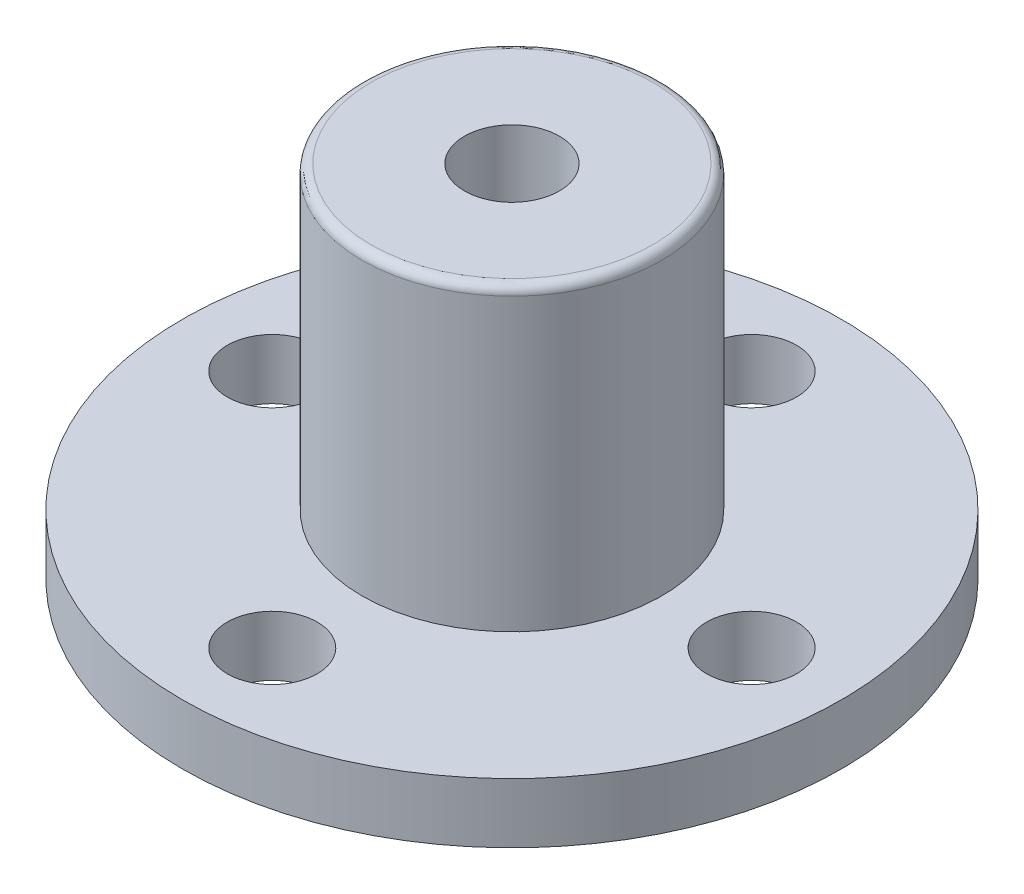
from build123d import *

# Parameters (mm, degrees)
SKETCH1_R           = 11
BOSS_EXTRUDE1_DEPTH = 2
SKETCH2_R           = 5
BOSS_EXTRUDE2_DEPTH = 10
FILLET1_R           = 0.3
SKETCH3_R           = 1.5
CUT_EXTRUDE1_DEPTH  = 10
SKETCH4_R           = 1.585
CUT_EXTRUDE2_DEPTH  = 20


with BuildPart() as part:
    # Sketch1 → Boss-Extrude1 (new body)
    with BuildSketch(Plane(origin=(0, 0, 0), x_dir=(1, 0, 0), z_dir=(0, 1, 0))):
        Circle(SKETCH1_R)
    extrude(amount=BOSS_EXTRUDE1_DEPTH)

    # Sketch2 → Boss-Extrude2 (add)
    with BuildSketch(Plane(origin=(0, 2, 0), x_dir=(1, 0, 0), z_dir=(0, 1, 0))):
        Circle(SKETCH2_R)
    extrude(amount=BOSS_EXTRUDE2_DEPTH)

    # Fillet1
    fillet1_edges = [part.edges().sort_by_distance(p)[0] for p in [
        (-5, 12, 0),
    ]]
    fillet(fillet1_edges, radius=FILLET1_R)

    # Sketch3 → Cut-Extrude1 (cut)
    with BuildSketch(Plane(origin=(0, 2, 0), x_dir=(1, 0, 0), z_dir=(0, 1, 0))):
        with Locations((0, 8)):
            Circle(SKETCH3_R)
        with Locations((8, 0)):
            Circle(SKETCH3_R)
        with Locations((0, -8)):
            Circle(SKETCH3_R)
        with Locations((-8, 0)):
            Circle(SKETCH3_R)
    extrude(amount=-CUT_EXTRUDE1_DEPTH, mode=Mode.SUBTRACT)

    # Sketch4 → Cut-Extrude2 (cut)
    with BuildSketch(Plane(origin=(0, 12, 0), x_dir=(1, 0, 0), z_dir=(0, 1, 0))):
        Circle(SKETCH4_R)
    extrude(amount=-CUT_EXTRUDE2_DEPTH, mode=Mode.SUBTRACT)


solid = part.part
